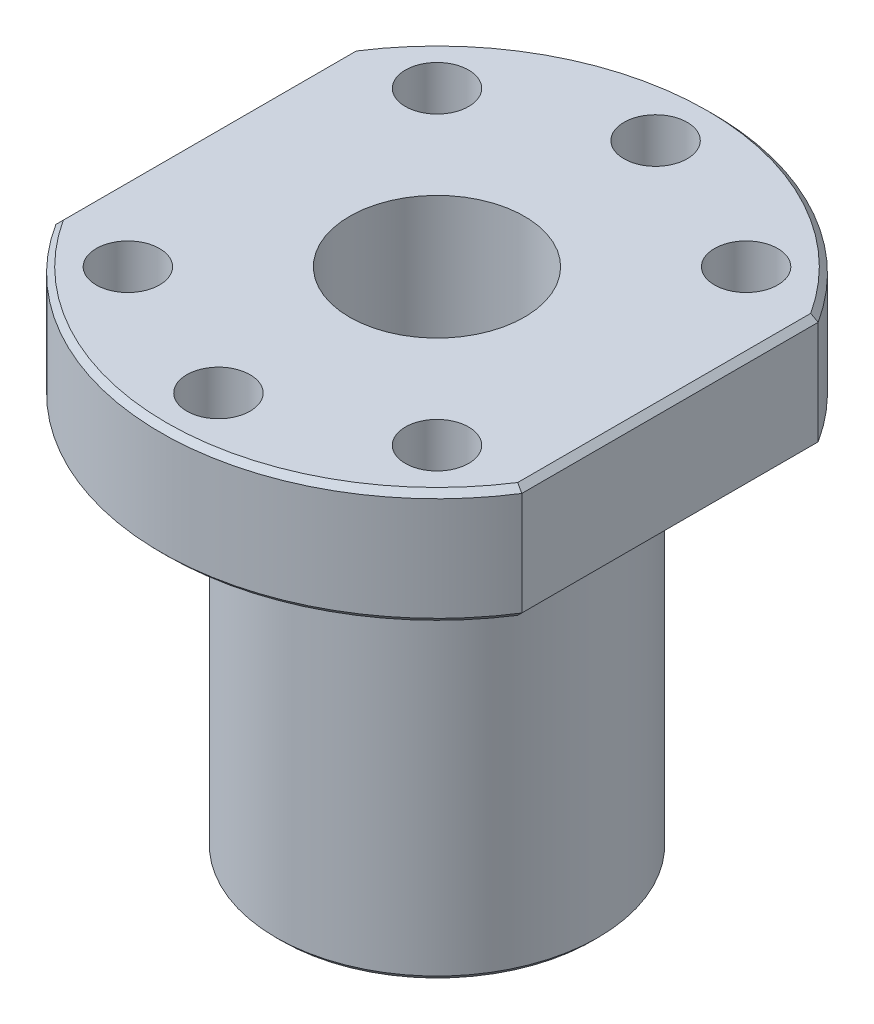
from build123d import *

# Parameters (mm, degrees)
SKETCH_1_R          = 14
EXTRUDE_1_DEPTH     = 34
SKETCH_2_R          = 2.75
EXTRUDE_2_DEPTH     = 10
SKETCH_3_R          = 7.6
CUT_EXTRUDE_1_DEPTH = 45
CHAMFER_1_SIZE      = 0.5


with BuildPart() as part:
    # Эскиз1 → Бобышка-Вытянуть1 (new body)
    with BuildSketch(Plane(origin=(0, 0, 0), x_dir=(1, 0, 0), z_dir=(0, 1, 0))):
        Circle(SKETCH_1_R)
    extrude(amount=EXTRUDE_1_DEPTH)

    # Эскиз2 → Бобышка-Вытянуть2 (add)
    with BuildSketch(Plane(origin=(0, 34, 0), x_dir=(1, 0, 0), z_dir=(0, 1, 0))):
        with BuildLine():
            Line((-20.25, -12.881673028), (-20.25, 12.881673028))
            ThreePointArc((-20.25, 12.881673028), (0, 24), (20.25, 12.881673028))
            Line((20.25, 12.881673028), (20.25, -12.881673028))
            ThreePointArc((20.25, -12.881673028), (0, -24), (-20.25, -12.881673028))
        make_face()
        with Locations((0, 19)):
            Circle(SKETCH_2_R, mode=Mode.SUBTRACT)
        with Locations((13.435028843, 13.435028843)):
            Circle(SKETCH_2_R, mode=Mode.SUBTRACT)
        with Locations((13.435028843, -13.435028843)):
            Circle(SKETCH_2_R, mode=Mode.SUBTRACT)
        with Locations((0, -19)):
            Circle(SKETCH_2_R, mode=Mode.SUBTRACT)
        with Locations((-13.435028843, -13.435028843)):
            Circle(SKETCH_2_R, mode=Mode.SUBTRACT)
        with Locations((-13.435028843, 13.435028843)):
            Circle(SKETCH_2_R, mode=Mode.SUBTRACT)
    extrude(amount=EXTRUDE_2_DEPTH)

    # Эскиз3 → Вырез-Вытянуть1 (cut, through all)
    with BuildSketch(Plane(origin=(0, 44, 0), x_dir=(1, 0, 0), z_dir=(0, 1, 0))):
        Circle(SKETCH_3_R)
    extrude(amount=-CUT_EXTRUDE_1_DEPTH, mode=Mode.SUBTRACT)

    # Фаска1
    chamfer_1_edges = [part.edges().sort_by_distance(p)[0] for p in [
        (-14, 0, 0),
        (0, 44, -24),
        (-20.25, 44, 0),
        (0, 44, 24),
        (20.25, 44, 0),
        (0, 34, -24),
        (-20.25, 34, 0),
        (0, 34, 24),
        (20.25, 34, 0),
    ]]
    chamfer(chamfer_1_edges, length=CHAMFER_1_SIZE)


solid = part.part
